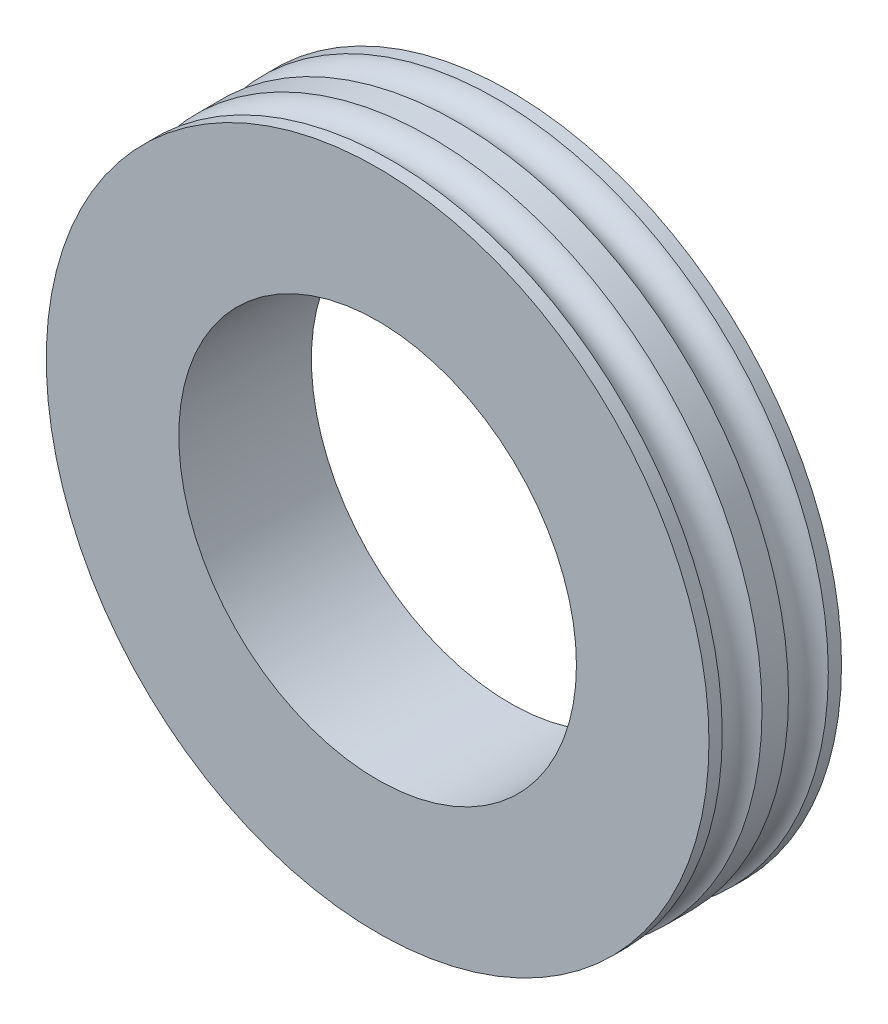
from build123d import *


with BuildPart() as part:
    # Sketch2 → Revolve1 (revolve)
    with BuildSketch(Plane(origin=(0, 0, 0), x_dir=(0, 0, -1), z_dir=(1, 0, 0))):
        with BuildLine():
            Line((0, 3), (0, 5))
            Line((0, 5), (-0.2, 5))
            ThreePointArc((-0.2, 5), (-0.5, 4.783772234), (-0.8, 5))
            Line((-0.8, 5), (-1, 5))
            Line((-1, 5), (-1, 3))
            Line((-1, 3), (0, 3))
        make_face()
    revolve1 = revolve(axis=Axis((0, 0, 3.014677367), (0, 0, -1)))

    # Mirror2: Revolve1 across plane
    add(revolve1.mirror(Plane(origin=(0, 0, 0), x_dir=(1, 0, 0), z_dir=(0, 0, -1))))


solid = part.part
